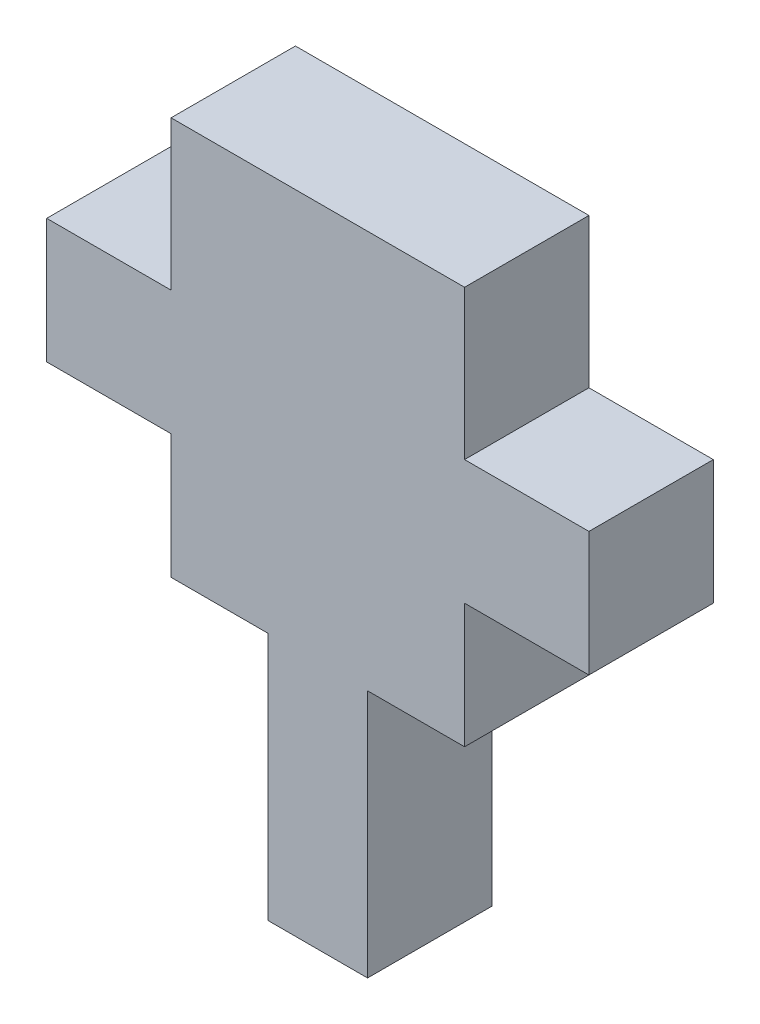
from build123d import *

# Parameters (mm, degrees)
ESQUISSE1_W        = 4
ESQUISSE1_H        = 10
ESQUISSE1_W_2      = 5
ESQUISSE1_H_2      = 5
ESQUISSE1_W_3      = 11.8
ESQUISSE1_H_3      = 16
BOSS_EXTRU_1_DEPTH = 5


with BuildPart() as part:
    # Esquisse1 → Boss.-Extru.1 (new body)
    with BuildSketch(Plane.XY):
        with Locations((5.9, -5)):
            Rectangle(ESQUISSE1_W, ESQUISSE1_H)
        with Locations((-2.5, 7.5)):
            Rectangle(ESQUISSE1_W_2, ESQUISSE1_H_2)
        with Locations((5.9, 8)):
            Rectangle(ESQUISSE1_W_3, ESQUISSE1_H_3)
        with Locations((14.3, 7.5)):
            Rectangle(ESQUISSE1_W_2, ESQUISSE1_H_2)
    extrude(amount=BOSS_EXTRU_1_DEPTH)


solid = part.part
